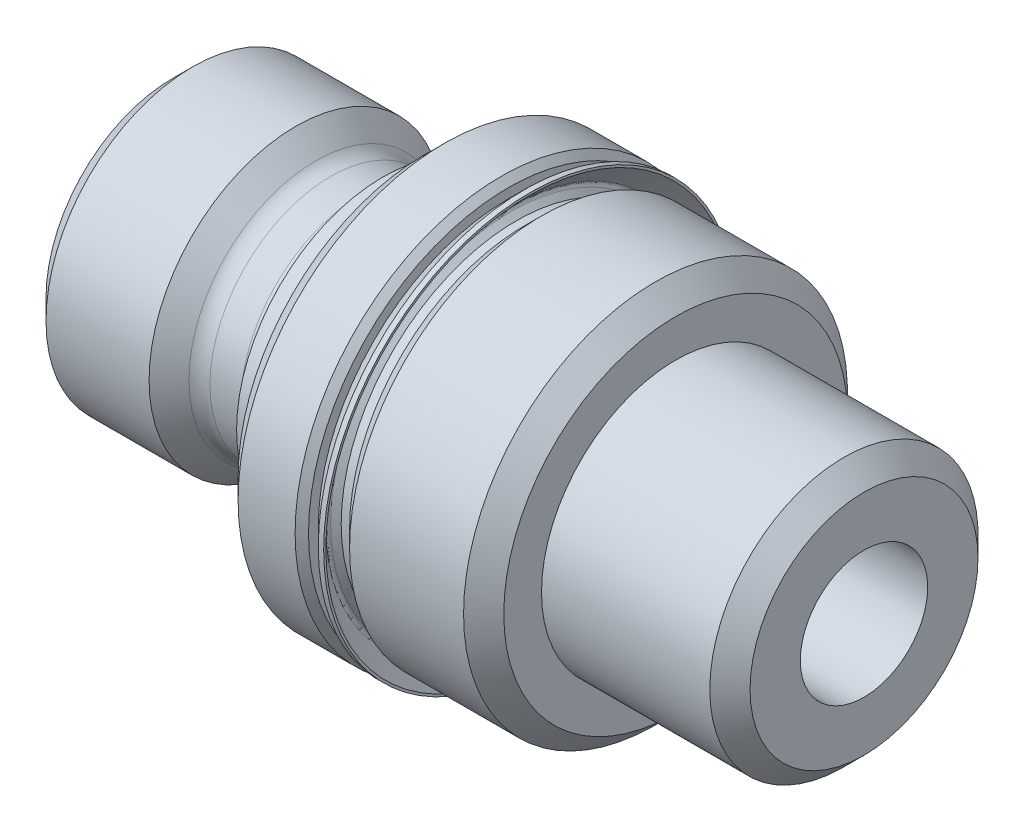
from build123d import *

# Parameters (mm, degrees)
HOLE1_D           = 4.826
HOLE1_CSINK_D     = 5.842
HOLE1_CSINK_ANGLE = 90


with BuildPart() as part:
    # Sketch1 → Revolve1 (revolve)
    with BuildSketch(Plane.XY):
        with BuildLine():
            Line((0, 0), (0, 4.8006))
            Line((0, 4.8006), (0.75565, 5.55625))
            Line((0.75565, 5.55625), (4.660293864, 5.55625))
            Line((4.660293864, 5.55625), (5.418103291, 4.804192648))
            ThreePointArc((5.418103291, 4.804192648), (5.676923575, 4.6323221), (5.9817, 4.572))
            Line((5.9817, 4.572), (7.1501, 4.572))
            ThreePointArc((7.1501, 4.572), (7.715856136, 4.806343864), (7.9502, 5.3721))
            Line((7.9502, 5.3721), (7.9502, 5.53085))
            Line((7.9502, 5.53085), (9.525, 5.53085))
            Line((9.525, 5.53085), (9.525, 0))
            Line((9.525, 0), (0, 0))
        make_face()
    revolve(axis=Axis((9.525, 0, 0), (-1, 0, 0)))

    # Sketch2 → Revolve2 (revolve)
    with BuildSketch(Plane.XY):
        Polygon((9.525, 0), (9.525, 7.0485), (10.287, 7.8105), (12.446, 7.8105), (12.7, 7.5565), (12.7, 6.63575), (13.335, 6.63575), (13.97, 7.27075), (18.288, 7.27075), (19.05, 6.50875), (19.05, 0), align=None)
    revolve(axis=Axis((19.05, 0, 0), (-1, 0, 0)))

    # Sketch3 → Revolve3 (revolve)
    with BuildSketch(Plane.XY):
        Polygon((19.05, 0), (19.05, 5.08), (25.4254, 5.08), (26.1874, 4.318), (26.1874, 0), align=None)
    revolve(axis=Axis((26.1874, 0, 0), (-1, 0, 0)))

    # Hole1 (through all)
    with Locations(Plane.ZY):
        with Locations((0, 0)):
            CounterSinkHole(HOLE1_D / 2, HOLE1_CSINK_D / 2, counter_sink_angle=HOLE1_CSINK_ANGLE)

    # Sketch6 → Revolve4 (revolve)
    with BuildSketch(Plane.XY):
        with BuildLine():
            Line((12.7, 6.38175), (13.335, 6.38175))
            Line((13.335, 6.38175), (13.335, 6.63575))
            Line((13.335, 6.63575), (13.0175, 6.63575))
            Line((13.0175, 6.63575), (12.817039755, 6.836210245))
            ThreePointArc((12.817039755, 6.836210245), (12.779842316, 6.926012806), (12.817039755, 7.015815367))
            Line((12.817039755, 7.015815367), (13.527556192, 7.726331804))
            Line((13.527556192, 7.726331804), (13.527556192, 7.8105))
            Line((13.527556192, 7.8105), (13.324356192, 7.8105))
            Line((13.324356192, 7.8105), (12.7, 7.186143808))
            Line((12.7, 7.186143808), (12.7, 6.38175))
        make_face()
    revolve(axis=Axis((13.335, 0, 0), (-1, 0, 0)))


solid = part.part
